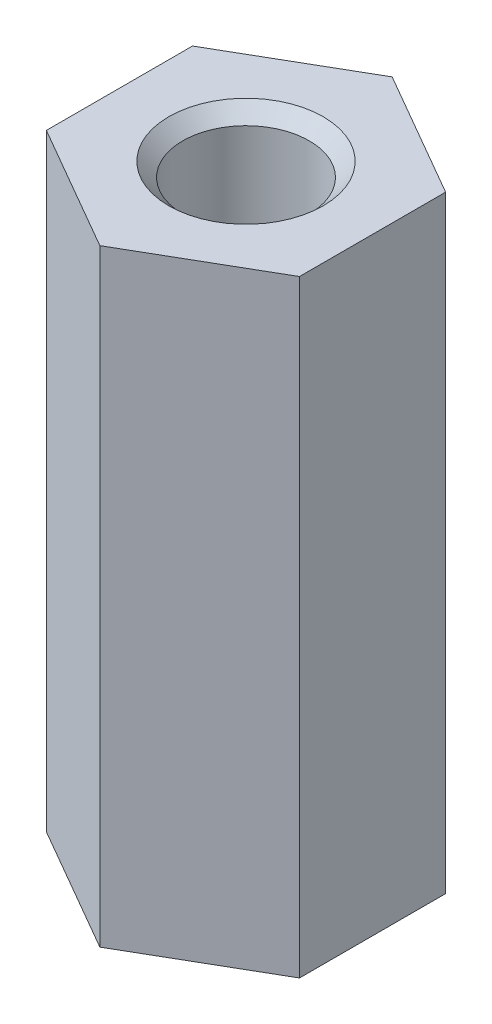
from build123d import *

# Parameters (mm, degrees)
BOSS_EXTRUDE1_DEPTH         = 12
M3_TAPPED_HOLE1_D           = 2.5
M3_TAPPED_HOLE1_DEPTH       = 7.5
M3_TAPPED_HOLE1_CSINK_D     = 3.05
M3_TAPPED_HOLE1_CSINK_ANGLE = 90
M3_TAPPED_HOLE1_TIP         = 0.751075774
M3_TAPPED_HOLE2_D           = 2.5
M3_TAPPED_HOLE2_DEPTH       = 7.5
M3_TAPPED_HOLE2_CSINK_D     = 3.05
M3_TAPPED_HOLE2_CSINK_ANGLE = 90
M3_TAPPED_HOLE2_TIP         = 0.751075774


with BuildPart() as part:
    # Sketch1 → Boss-Extrude1 (new body)
    with BuildSketch(Plane(origin=(0, 0, 0), x_dir=(1, 0, 0), z_dir=(0, 1, 0))):
        Polygon((-2.5, 1.443375673), (-2.5, -1.443375673), (0, -2.886751346), (2.5, -1.443375673), (2.5, 1.443375673), (0, 2.886751346), align=None)
    extrude(amount=BOSS_EXTRUDE1_DEPTH)

    # M3 Tapped Hole1
    with Locations(Plane(origin=(0, 12, 0), x_dir=(1, 0, 0), z_dir=(0, 1, 0))):
        with Locations((0, 0)):
            CounterSinkHole(M3_TAPPED_HOLE1_D / 2, M3_TAPPED_HOLE1_CSINK_D / 2, depth=M3_TAPPED_HOLE1_DEPTH, counter_sink_angle=M3_TAPPED_HOLE1_CSINK_ANGLE)
            with Locations((0, 0, -(M3_TAPPED_HOLE1_DEPTH + M3_TAPPED_HOLE1_TIP / 2))):  # 118° drill point
                Cone(0, M3_TAPPED_HOLE1_D / 2, M3_TAPPED_HOLE1_TIP, mode=Mode.SUBTRACT)

    # M3 Tapped Hole2
    with Locations(Plane(origin=(0, 0, 0), x_dir=(-1, 0, 0), z_dir=(0, -1, 0))):
        with Locations((0, 0)):
            CounterSinkHole(M3_TAPPED_HOLE2_D / 2, M3_TAPPED_HOLE2_CSINK_D / 2, depth=M3_TAPPED_HOLE2_DEPTH, counter_sink_angle=M3_TAPPED_HOLE2_CSINK_ANGLE)
            with Locations((0, 0, -(M3_TAPPED_HOLE2_DEPTH + M3_TAPPED_HOLE2_TIP / 2))):  # 118° drill point
                Cone(0, M3_TAPPED_HOLE2_D / 2, M3_TAPPED_HOLE2_TIP, mode=Mode.SUBTRACT)


solid = part.part
